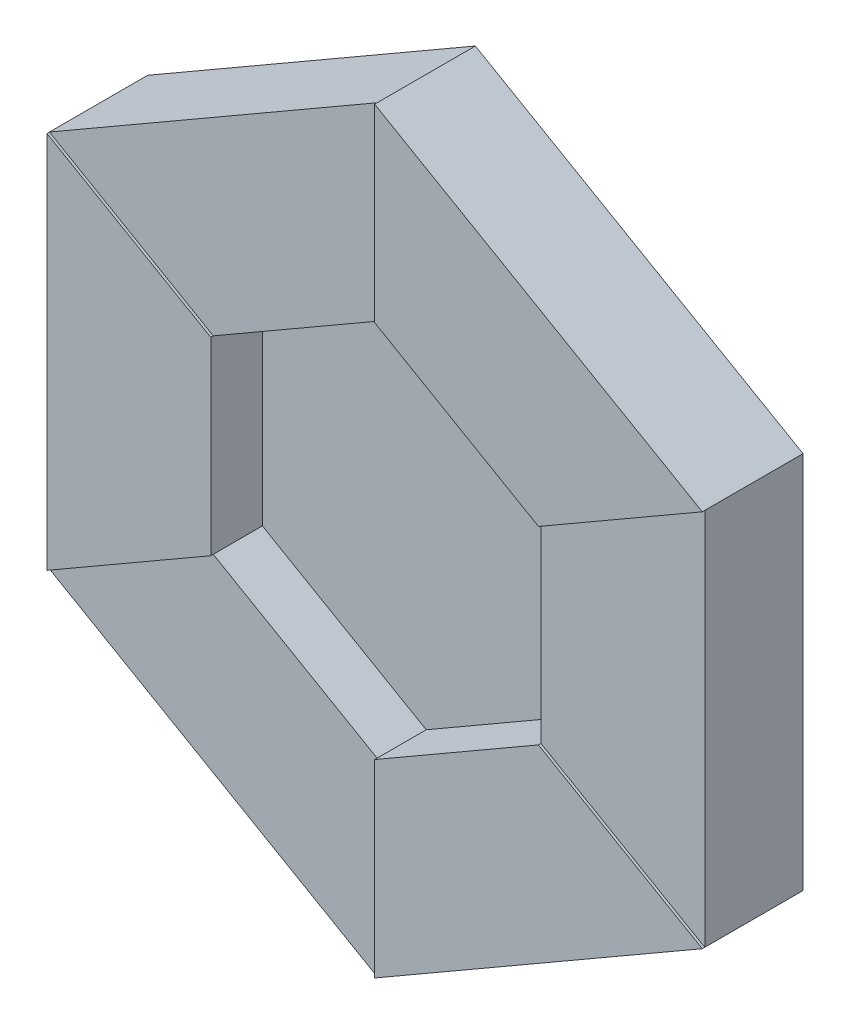
from build123d import *

# Parameters (mm, degrees)
BOSS_EXTRUDE1_DEPTH   = 30
BODY_MOVE_COPY1_ANGLE = 60
SCALE1_SCALE_X        = 1
SCALE1_SCALE_Y        = 1
SCALE1_SCALE_Z        = 1.1
CIRPATTERN2_COUNT     = 3
BOSS_EXTRUDE3_DEPTH   = 30


with BuildPart() as part:
    # Sketch1 → Boss-Extrude1 (new body)
    with BuildSketch(Plane.XY):
        Polygon((200, -115.470053838), (200, 115.470053838), (100, 57.735026919), (100, -57.735026919), align=None)
    extrude(amount=BOSS_EXTRUDE1_DEPTH)


with BuildPart() as body_2:
    # Body-Move_Copy1: copy of part
    add(part.part.rotate(Axis((0, 0, 0), (0, 0, 1)), BODY_MOVE_COPY1_ANGLE))


with BuildPart() as body_2_1:
    # Scale1: scaled about (77.777777778, 134.715062811, 15)
    add(body_2.part.scale((SCALE1_SCALE_X, SCALE1_SCALE_Y, SCALE1_SCALE_Z), about=(77.777777778, 134.715062811, 15)))

    # Combine1: union part
    add(part.part)


with BuildPart() as cirpattern2_1:
    # CirPattern2: pattern copy
    add(body_2_1.part.rotate(Axis((0, 0, -1.5), (0, 0, 1)), 1 * 360 / CIRPATTERN2_COUNT))


with BuildPart() as cirpattern2_2:
    # CirPattern2: pattern copy
    add(body_2_1.part.rotate(Axis((0, 0, -1.5), (0, 0, 1)), 2 * 360 / CIRPATTERN2_COUNT))


with BuildPart() as body_2_2:
    add(body_2_1.part)

    add(cirpattern2_1.part)  # Boss-Extrude3 merges CirPattern2_1

    add(cirpattern2_2.part)  # Boss-Extrude3 merges CirPattern2_2
    # Sketch2 → Boss-Extrude3 (add)
    with BuildSketch(Plane(origin=(0, 0, 0), x_dir=(-1, 0, 0), z_dir=(0, 0, -1))):
        Polygon((-200, 115.470053838), (0, 230.940107676), (200, 115.470053838), (200, -115.470053838), (0, -230.940107676), (-200, -115.470053838), align=None)
    extrude(amount=BOSS_EXTRUDE3_DEPTH)


solid = body_2_2.part
